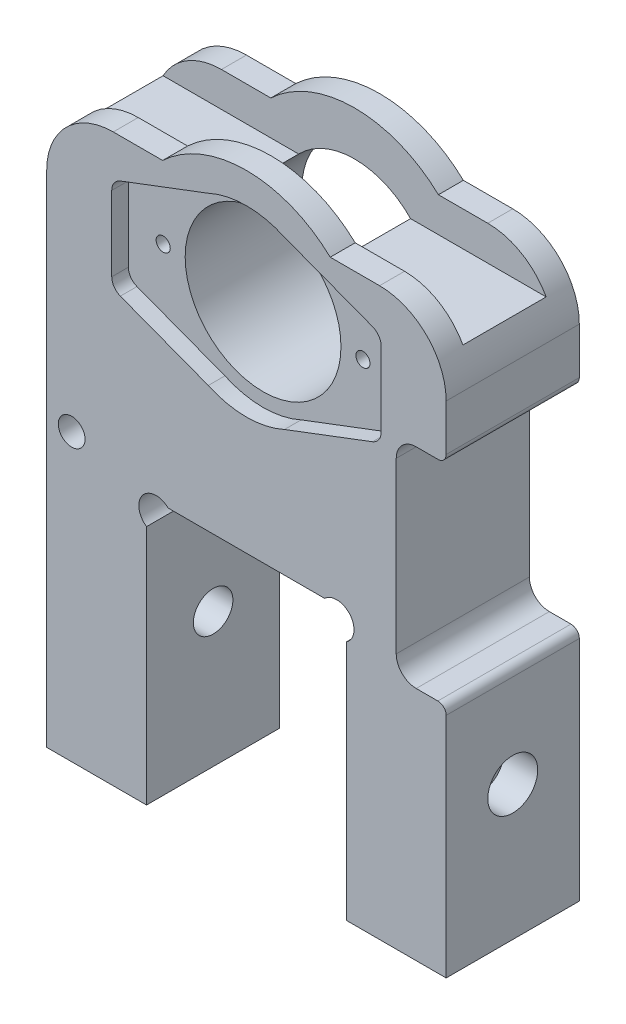
from build123d import *

# Parameters (mm, degrees)
SKETCH1_R               = 14.859
SKETCH1_R_2             = 2.5527
BOSS_EXTRUDE1_DEPTH     = 25.4
FILLET1_R               = 12.7
CUT_EXTRUDE1_DEPTH      = 3.175
FILLET2_R               = 2.54
SKETCH3_R               = 1.3462
CUT_EXTRUDE2_DEPTH      = 22.225
CUT_EXTRUDE3_START      = -76.2
SKETCH4_R               = 3.7703125
CUT_EXTRUDE3_DEPTH      = 76.2
SKETCH5_W               = 85.90580112
SKETCH5_H               = 15.875
CUT_EXTRUDE4_DEPTH      = 23.622
CUT_EXTRUDE4_DEPTH_BACK = 6.604
CUT_EXTRUDE5_START      = -25.4
SKETCH6_W               = 9.525
SKETCH6_H               = 39.923791379
CUT_EXTRUDE5_DEPTH      = 25.4
FILLET3_R               = 3.81
FILLET4_R               = 1.5875
SKETCH7_R               = 4.7625
CUT_EXTRUDE6_DEPTH      = 6.35


with BuildPart() as part:
    # Sketch1 → Boss-Extrude1 (new body)
    with BuildSketch(Plane.XY):
        with BuildLine():
            Line((38.1, -57.15), (19.05, -57.15))
            Line((19.05, -57.15), (19.05, -11.154684967))
            ThreePointArc((19.05, -11.154684967), (19.796266411, -6.337498405), (14.931562131, -6.026287555))
            Line((14.931562131, -6.026287555), (-14.931562131, -6.026287555))
            ThreePointArc((-14.931562131, -6.026287555), (-19.796266411, -6.337498405), (-19.05, -11.154684967))
            Line((-19.05, -11.154684967), (-19.05, -57.15))
            Line((-19.05, -57.15), (-38.1, -57.15))
            Line((-38.1, -57.15), (-38.1, 50.869712445))
            Line((-38.1, 50.869712445), (-15.983846846, 50.869712445))
            ThreePointArc((-15.983846846, 50.869712445), (0, 57.219712445), (15.983846846, 50.869712445))
            Line((15.983846846, 50.869712445), (38.1, 50.869712445))
            Line((38.1, 50.869712445), (38.1, -57.15))
        make_face()
        with Locations((0, 33.927912445)):
            Circle(SKETCH1_R, mode=Mode.SUBTRACT)
        with Locations((-33.3375, -2.611452402)):
            Circle(SKETCH1_R_2, mode=Mode.SUBTRACT)
        with Locations((33.3375, -2.611452402)):
            Circle(SKETCH1_R_2, mode=Mode.SUBTRACT)
    extrude(amount=BOSS_EXTRUDE1_DEPTH)

    # Fillet1
    fillet1_edges = [part.edges().sort_by_distance(p)[0] for p in [
        (-38.1, 50.869712445, 12.7),
        (38.1, 50.869712445, 12.7),
    ]]
    fillet(fillet1_edges, radius=FILLET1_R)

    # Sketch2 → Cut-Extrude1 (cut)
    with BuildSketch(Plane.XY.offset(25.4)):
        with BuildLine():
            Line((25.6921, 25.037912445), (25.6921, 42.817912445))
            Line((25.6921, 42.817912445), (7.274838916, 49.802912445))
            ThreePointArc((7.274838916, 49.802912445), (0, 51.390412445), (-7.274838916, 49.802912445))
            Line((-7.274838916, 49.802912445), (-25.6921, 42.817912445))
            Line((-25.6921, 42.817912445), (-25.6921, 25.037912445))
            Line((-25.6921, 25.037912445), (-7.274838916, 18.052912445))
            ThreePointArc((-7.274838916, 18.052912445), (0, 16.465412445), (7.274838916, 18.052912445))
            Line((7.274838916, 18.052912445), (25.6921, 25.037912445))
        make_face()
    extrude(amount=-CUT_EXTRUDE1_DEPTH, mode=Mode.SUBTRACT)

    # Fillet2
    fillet2_edges = [part.edges().sort_by_distance(p)[0] for p in [
        (-25.6921, 42.817912445, 23.8125),
        (25.6921, 42.817912445, 23.8125),
        (25.6921, 25.037912445, 23.8125),
        (-25.6921, 25.037912445, 23.8125),
    ]]
    fillet(fillet2_edges, radius=FILLET2_R)

    # Sketch3 → Cut-Extrude2 (cut)
    with BuildSketch(Plane.XY.offset(22.225)):
        with Locations((-19.05, 33.927912445)):
            Circle(SKETCH3_R)
        with Locations((19.05, 33.927912445)):
            Circle(SKETCH3_R)
    extrude(amount=-CUT_EXTRUDE2_DEPTH, mode=Mode.SUBTRACT)

    # Sketch4 → Cut-Extrude3 (cut)
    with BuildSketch(Plane.ZY.offset(38.1).offset(CUT_EXTRUDE3_START)):
        with Locations((12.7, -31.496)):
            Circle(SKETCH4_R)
    extrude(amount=CUT_EXTRUDE3_DEPTH, mode=Mode.SUBTRACT)

    # Sketch5 → Cut-Extrude4 (cut, two sides)
    with BuildSketch(Plane(origin=(0, 50.869712445, 0), x_dir=(1, 0, 0), z_dir=(0, 1, 0))) as cut_extrude4_sk:
        with Locations((0, -12.7)):
            Rectangle(SKETCH5_W, SKETCH5_H)
    extrude(amount=CUT_EXTRUDE4_DEPTH, mode=Mode.SUBTRACT)
    extrude(cut_extrude4_sk.sketch, amount=-CUT_EXTRUDE4_DEPTH_BACK, mode=Mode.SUBTRACT)

    # Sketch6 → Cut-Extrude5 (cut)
    with BuildSketch(Plane(origin=(0, 0, 0), x_dir=(-1, 0, 0), z_dir=(0, 0, -1)).offset(CUT_EXTRUDE5_START)):
        with Locations((-33.3375, 7.785139318)):
            Rectangle(SKETCH6_W, SKETCH6_H)
    extrude(amount=CUT_EXTRUDE5_DEPTH, mode=Mode.SUBTRACT)

    # Fillet3
    fillet3_edges = [part.edges().sort_by_distance(p)[0] for p in [
        (28.575, 27.747035008, 12.7),
        (28.575, -12.176756371, 12.7),
    ]]
    fillet(fillet3_edges, radius=FILLET3_R)

    # Fillet4
    fillet4_edges = [part.edges().sort_by_distance(p)[0] for p in [
        (38.1, -12.176756371, 12.7),
        (38.1, 27.747035008, 12.7),
    ]]
    fillet(fillet4_edges, radius=FILLET4_R)

    # Sketch7 → Cut-Extrude6 (cut)
    with BuildSketch(Plane(origin=(38.1, 0, 0), x_dir=(0, 0, -1), z_dir=(1, 0, 0))):
        with Locations((-12.7, -31.496)):
            Circle(SKETCH7_R)
    cut_extrude6 = extrude(amount=-CUT_EXTRUDE6_DEPTH, mode=Mode.SUBTRACT)

    # Mirror1: Cut-Extrude6 across plane
    add(cut_extrude6.mirror(Plane(origin=(0, 0, 0), x_dir=(0, 0, 1), z_dir=(1, 0, 0))), mode=Mode.SUBTRACT)


solid = part.part
